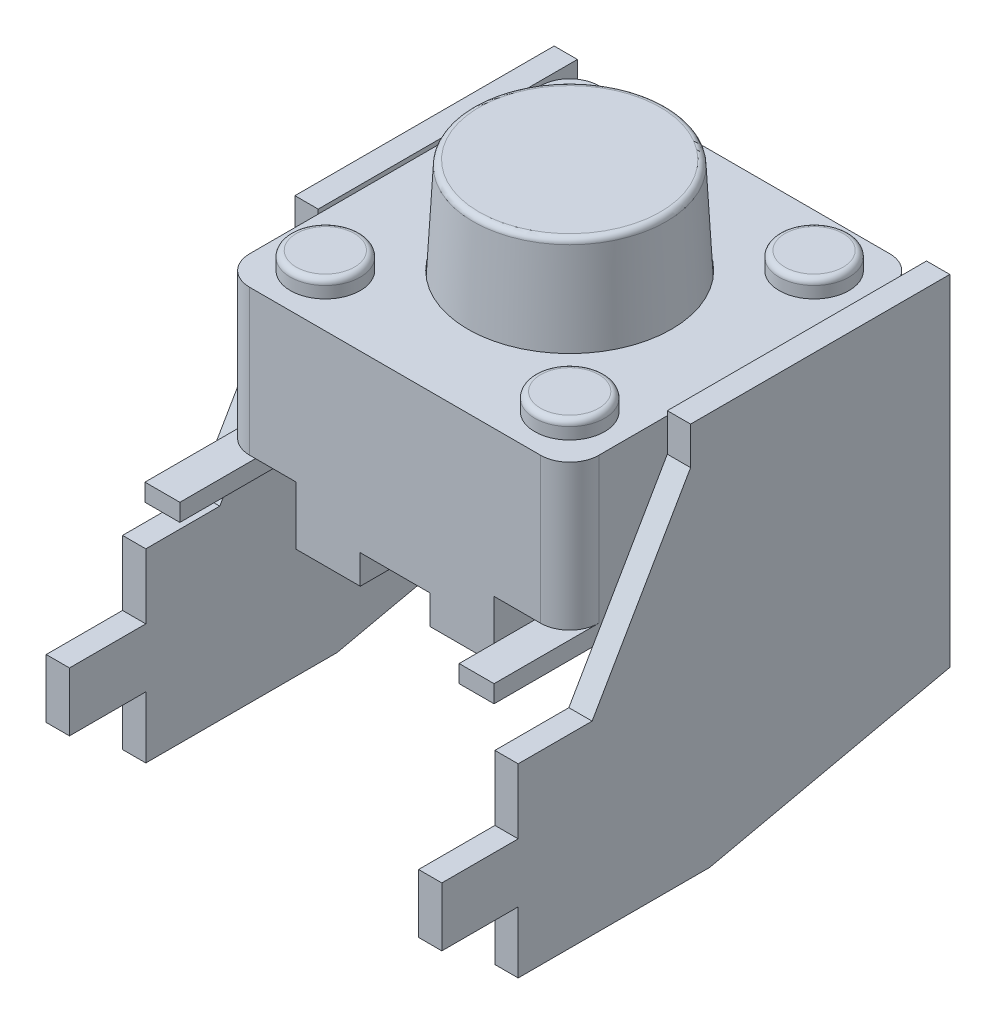
from build123d import *

# Parameters (mm, degrees)
SKETCH1_W                 = 0.6
SKETCH1_H                 = 0.3
SKETCH1_R                 = 0.6
SKETCH1_R_2               = 1.75
BASE_DEPTH                = 3.3
TOP_START                 = 3.3
SKETCH1_3_R               = 0.6
SKETCH1_3_R_2             = 1.75
SKETCH1_3_W               = 0.6
SKETCH1_3_H               = 0.3
TOP_PLATE_DEPTH           = 0.2
KNOBS_START               = 3.3
SKETCH1_4_R               = 0.6
KNOBS_DEPTH               = 0.5
ACTUATOR_START            = 3.3
SKETCH1_5_R               = 1.75
ACTUATOR_DEPTH            = 1.85
ACTUATOR_TAPER            = 3
BASE_START                = -1
BASE_LEG_CUTOUT_DEPTH     = 1
SKETCH2_3_W               = 1.2
SKETCH2_3_H               = 6
SKETCH2_3_W_2             = 1.3
SKETCH2_3_H_2             = 1.1
BASE_SHALLOW_CUTOUT_DEPTH = 0.5
PINS_START                = 1
SKETCH1_7_W               = 0.6
SKETCH1_7_H               = 0.3
PINS_DEPTH                = 0.3
PINS_2_DEPTH              = 0.3
FILLET1_R                 = 0.1
FILLET2_R                 = 0.1
SKETCH4_W                 = 0.6
SKETCH4_H                 = 0.3
BOSS_EXTRUDE1_DEPTH       = 4
BOSS_EXTRUDE2_DEPTH       = 0.4
BOSS_EXTRUDE3_DEPTH       = 0.4
SKETCH8_W                 = 2.370971926
SKETCH8_H                 = 1.011910634
CUT_EXTRUDE1_DEPTH        = 1
CUT_EXTRUDE1_DEPTH_BACK   = 7.8


with BuildPart() as part:
    # Sketch1 → Base (new body)
    with BuildSketch(Plane(origin=(0, 0, 0), x_dir=(1, 0, 0), z_dir=(0, 1, 0))):
        with Locations((-2.7, -0.15)):
            Rectangle(SKETCH1_W, SKETCH1_H)
        with BuildLine():
            Line((2.5, 3), (-2.5, 3))
            ThreePointArc((-2.5, 3), (-2.853553391, 2.853553391), (-3, 2.5))
            Line((-3, 2.5), (-3, 0))
            Line((-3, 0), (-2.4, 0))
            Line((-2.4, 0), (-2.4, -0.3))
            Line((-2.4, -0.3), (-3, -0.3))
            Line((-3, -0.3), (-3, -2.5))
            ThreePointArc((-3, -2.5), (-2.853553391, -2.853553391), (-2.5, -3))
            Line((-2.5, -3), (2.5, -3))
            ThreePointArc((2.5, -3), (2.853553391, -2.853553391), (3, -2.5))
            Line((3, -2.5), (3, -0.3))
            Line((3, -0.3), (2.4, -0.3))
            Line((2.4, -0.3), (2.4, 0))
            Line((2.4, 0), (3, 0))
            Line((3, 0), (3, 2.5))
            ThreePointArc((3, 2.5), (2.853553391, 2.853553391), (2.5, 3))
        make_face()
        with Locations((-2.1, -2.1)):
            Circle(SKETCH1_R, mode=Mode.SUBTRACT)
        Circle(SKETCH1_R_2, mode=Mode.SUBTRACT)
        with Locations((2.1, -2.1)):
            Circle(SKETCH1_R, mode=Mode.SUBTRACT)
        with Locations((-2.1, 2.1)):
            Circle(SKETCH1_R, mode=Mode.SUBTRACT)
        with Locations((2.1, 2.1)):
            Circle(SKETCH1_R, mode=Mode.SUBTRACT)
        with Locations((-2.1, 2.1)):
            Circle(SKETCH1_R)
        with Locations((-2.1, -2.1)):
            Circle(SKETCH1_R)
        Circle(SKETCH1_R_2)
        with Locations((2.1, -2.1)):
            Circle(SKETCH1_R)
        with Locations((2.7, -0.15)):
            Rectangle(SKETCH1_W, SKETCH1_H)
        with Locations((2.1, 2.1)):
            Circle(SKETCH1_R)
    extrude(amount=BASE_DEPTH)

    # Sketch1_4 → Knobs (add)
    with BuildSketch(Plane(origin=(0, 0, 0), x_dir=(1, 0, 0), z_dir=(0, 1, 0)).offset(KNOBS_START)):
        with Locations((2.1, -2.1)):
            Circle(SKETCH1_4_R)
        with Locations((-2.1, -2.1)):
            Circle(SKETCH1_4_R)
        with Locations((-2.1, 2.1)):
            Circle(SKETCH1_4_R)
        with Locations((2.1, 2.1)):
            Circle(SKETCH1_4_R)
    extrude(amount=KNOBS_DEPTH)

    # Sketch2 → Base Leg Cutout (cut)
    with BuildSketch(Plane.XZ.offset(BASE_START)):
        with BuildLine():
            Line((-1.7, -0.4), (-1.7, 3))
            Line((-1.7, 3), (-2.5, 3))
            ThreePointArc((-2.5, 3), (-2.853553391, 2.853553391), (-3, 2.5))
            Line((-3, 2.5), (-3, -0.4))
            Line((-3, -0.4), (-1.7, -0.4))
        make_face()
        with BuildLine():
            Line((2.5, 3), (1.7, 3))
            Line((1.7, 3), (1.7, -0.4))
            Line((1.7, -0.4), (3, -0.4))
            Line((3, -0.4), (3, 2.5))
            ThreePointArc((3, 2.5), (2.853553391, 2.853553391), (2.5, 3))
        make_face()
    extrude(amount=BASE_LEG_CUTOUT_DEPTH, mode=Mode.SUBTRACT)

    # Sketch2_3 → Base Shallow Cutout (cut)
    with BuildSketch(Plane.XZ):
        Rectangle(SKETCH2_3_W, SKETCH2_3_H)
        with Locations((2.35, -1.45)):
            Rectangle(SKETCH2_3_W_2, SKETCH2_3_H_2)
        with Locations((-2.35, -1.45)):
            Rectangle(SKETCH2_3_W_2, SKETCH2_3_H_2)
    extrude(amount=-BASE_SHALLOW_CUTOUT_DEPTH, mode=Mode.SUBTRACT)

    # Fillet2
    fillet2_edges = [part.edges().sort_by_distance(p)[0] for p in [
        (1.5, 3.8, 2.1),
        (-2.7, 3.8, 2.1),
        (-2.7, 3.8, -2.1),
        (1.5, 3.8, -2.1),
    ]]
    fillet(fillet2_edges, radius=FILLET2_R)



with BuildPart() as body_2:
    # Sketch1_3 → Top Plate (new body)
    with BuildSketch(Plane(origin=(0, 0, 0), x_dir=(1, 0, 0), z_dir=(0, 1, 0)).offset(TOP_START)):
        with BuildLine():
            Line((2.5, 3), (-2.5, 3))
            ThreePointArc((-2.5, 3), (-2.853553391, 2.853553391), (-3, 2.5))
            Line((-3, 2.5), (-3, 0))
            Line((-3, 0), (-2.4, 0))
            Line((-2.4, 0), (-2.4, -0.3))
            Line((-2.4, -0.3), (-3, -0.3))
            Line((-3, -0.3), (-3, -2.5))
            ThreePointArc((-3, -2.5), (-2.853553391, -2.853553391), (-2.5, -3))
            Line((-2.5, -3), (2.5, -3))
            ThreePointArc((2.5, -3), (2.853553391, -2.853553391), (3, -2.5))
            Line((3, -2.5), (3, -0.3))
            Line((3, -0.3), (2.4, -0.3))
            Line((2.4, -0.3), (2.4, 0))
            Line((2.4, 0), (3, 0))
            Line((3, 0), (3, 2.5))
            ThreePointArc((3, 2.5), (2.853553391, 2.853553391), (2.5, 3))
        make_face()
        with Locations((-2.1, -2.1)):
            Circle(SKETCH1_3_R, mode=Mode.SUBTRACT)
        Circle(SKETCH1_3_R_2, mode=Mode.SUBTRACT)
        with Locations((2.1, -2.1)):
            Circle(SKETCH1_3_R, mode=Mode.SUBTRACT)
        with Locations((-2.1, 2.1)):
            Circle(SKETCH1_3_R, mode=Mode.SUBTRACT)
        with Locations((2.1, 2.1)):
            Circle(SKETCH1_3_R, mode=Mode.SUBTRACT)
        with Locations((2.7, -0.15)):
            Rectangle(SKETCH1_3_W, SKETCH1_3_H)
        with Locations((-2.7, -0.15)):
            Rectangle(SKETCH1_3_W, SKETCH1_3_H)
    extrude(amount=TOP_PLATE_DEPTH)


with BuildPart() as body_3:
    # Sketch1_5 → Actuator (new body)
    with BuildSketch(Plane(origin=(0, 0, 0), x_dir=(1, 0, 0), z_dir=(0, 1, 0)).offset(ACTUATOR_START)):
        Circle(SKETCH1_5_R)
    extrude(amount=ACTUATOR_DEPTH, taper=ACTUATOR_TAPER)

    # Fillet1
    fillet1_edges = [body_3.edges().sort_by_distance(p)[0] for p in [
        (-1.653045608, 5.15, 0),
    ]]
    fillet(fillet1_edges, radius=FILLET1_R)


with BuildPart() as body_4:
    # Sketch1_7 → Pins (new body)
    with BuildSketch(Plane(origin=(0, 0, 0), x_dir=(1, 0, 0), z_dir=(0, 1, 0)).offset(PINS_START)):
        with Locations((-2.7, -0.15)):
            Rectangle(SKETCH1_7_W, SKETCH1_7_H)
    extrude(amount=-PINS_DEPTH)


with BuildPart() as body_5:
    # Sketch1_7 → Pins 2 (new body)
    with BuildSketch(Plane(origin=(0, 0, 0), x_dir=(1, 0, 0), z_dir=(0, 1, 0)).offset(PINS_START)):
        with Locations((2.7, -0.15)):
            Rectangle(SKETCH1_7_W, SKETCH1_7_H)
    extrude(amount=-PINS_2_DEPTH)


with BuildPart() as part_1:
    add(part.part)

    add(body_4.part)  # Boss-Extrude1 merges body 4

    add(body_5.part)  # Boss-Extrude1 merges body 5
    # Sketch4 → Boss-Extrude1 (add)
    with BuildSketch(Plane.XY.offset(0.3)):
        with Locations((2.7, 0.85)):
            Rectangle(SKETCH4_W, SKETCH4_H)
        with Locations((-2.7, 0.85)):
            Rectangle(SKETCH4_W, SKETCH4_H)
    extrude(amount=BOSS_EXTRUDE1_DEPTH)


    add(body_2.part)  # Boss-Extrude2 merges body 2
    # Sketch6 → Boss-Extrude2 (add)
    with BuildSketch(Plane(origin=(3, 0, 0), x_dir=(0, 0, -1), z_dir=(1, 0, 0))):
        with BuildLine():
            Line((3.132840684, 3.575039622), (3.132840684, -2.273948021))
            Line((3.132840684, -2.273948021), (-0.994663761, -3.188082912))
            Line((-0.994663761, -3.188082912), (-4.285578573, -3.188082912))
            Line((-4.285578573, -3.188082912), (-4.285578573, -2.128896003))
            Line((-4.285578573, -2.128896003), (-7.462436516, -2.128896003))
            ThreePointArc((-7.462436516, -2.128896003), (-7.968391833, -1.622940686), (-7.462436516, -1.116985369))
            Line((-7.462436516, -1.116985369), (-4.285578573, -1.116985369))
            Line((-4.285578573, -1.116985369), (-4.285578573, 0))
            Line((-4.285578573, 0), (-3.014513822, 0))
            Line((-3.014513822, 0), (-1.322453077, 2.926827881))
            Line((-1.322453077, 2.926827881), (-1.322453077, 3.575039622))
            Line((-1.322453077, 3.575039622), (3.132840684, 3.575039622))
        make_face()
    extrude(amount=BOSS_EXTRUDE2_DEPTH)

    # Sketch7 → Boss-Extrude3 (add)
    with BuildSketch(Plane.ZY.offset(3)):
        with BuildLine():
            Line((1.322453077, 3.575039622), (-3.132840684, 3.575039622))
            Line((-3.132840684, 3.575039622), (-3.132840684, -2.273948021))
            Line((-3.132840684, -2.273948021), (0.994663761, -3.188082912))
            Line((0.994663761, -3.188082912), (4.285578573, -3.188082912))
            Line((4.285578573, -3.188082912), (4.285578573, -2.128896003))
            Line((4.285578573, -2.128896003), (7.462436516, -2.128896003))
            ThreePointArc((7.462436516, -2.128896003), (7.968391833, -1.622940686), (7.462436516, -1.116985369))
            Line((7.462436516, -1.116985369), (4.285578573, -1.116985369))
            Line((4.285578573, -1.116985369), (4.285578573, 0))
            Line((4.285578573, 0), (3.014513822, 0))
            Line((3.014513822, 0), (1.322453077, 2.926827881))
            Line((1.322453077, 2.926827881), (1.322453077, 3.575039622))
        make_face()
    extrude(amount=BOSS_EXTRUDE3_DEPTH)

    # Sketch8 → Cut-Extrude1 (cut, two sides)
    with BuildSketch(Plane(origin=(3.4, 0, 0), x_dir=(0, 0, -1), z_dir=(1, 0, 0))) as cut_extrude1_sk:
        with Locations((-6.78290587, -1.622940686)):
            Rectangle(SKETCH8_W, SKETCH8_H)
    extrude(amount=CUT_EXTRUDE1_DEPTH, mode=Mode.SUBTRACT)
    extrude(cut_extrude1_sk.sketch, amount=-CUT_EXTRUDE1_DEPTH_BACK, mode=Mode.SUBTRACT)


solid = Compound([body_3.part, part_1.part])
